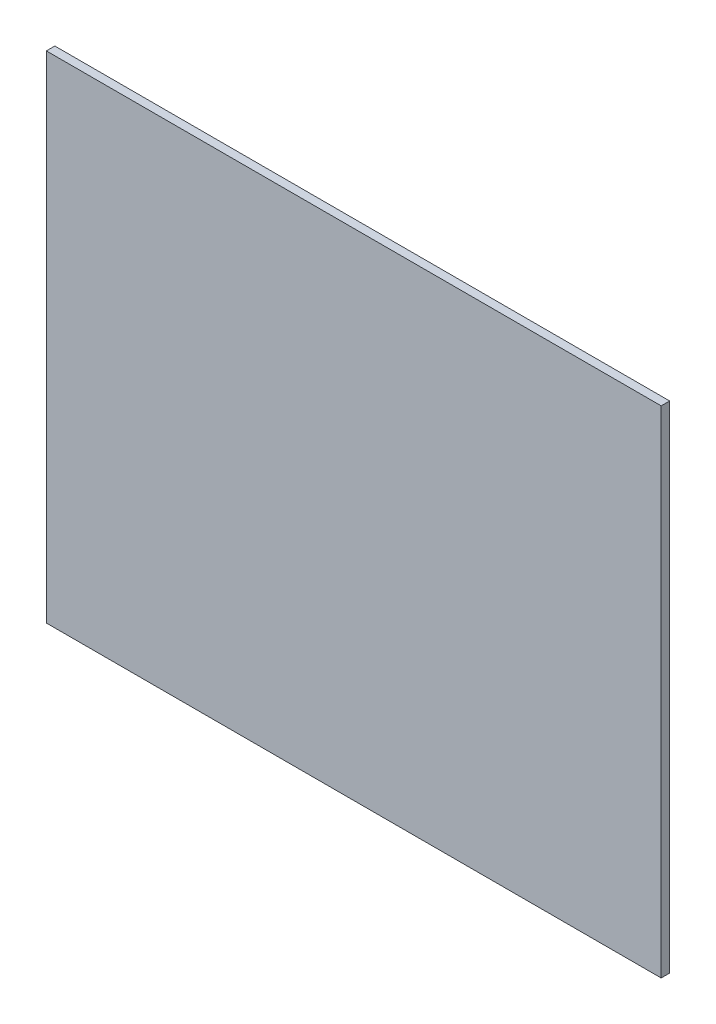
from build123d import *

# Parameters (mm, degrees)
SKETCH1_W           = 315.1632
SKETCH1_H           = 254
BOSS_EXTRUDE1_DEPTH = 4.3434


with BuildPart() as part:
    # Sketch1 → Boss-Extrude1 (new body)
    with BuildSketch(Plane.XY):
        Rectangle(SKETCH1_W, SKETCH1_H)
    extrude(amount=BOSS_EXTRUDE1_DEPTH)


solid = part.part
